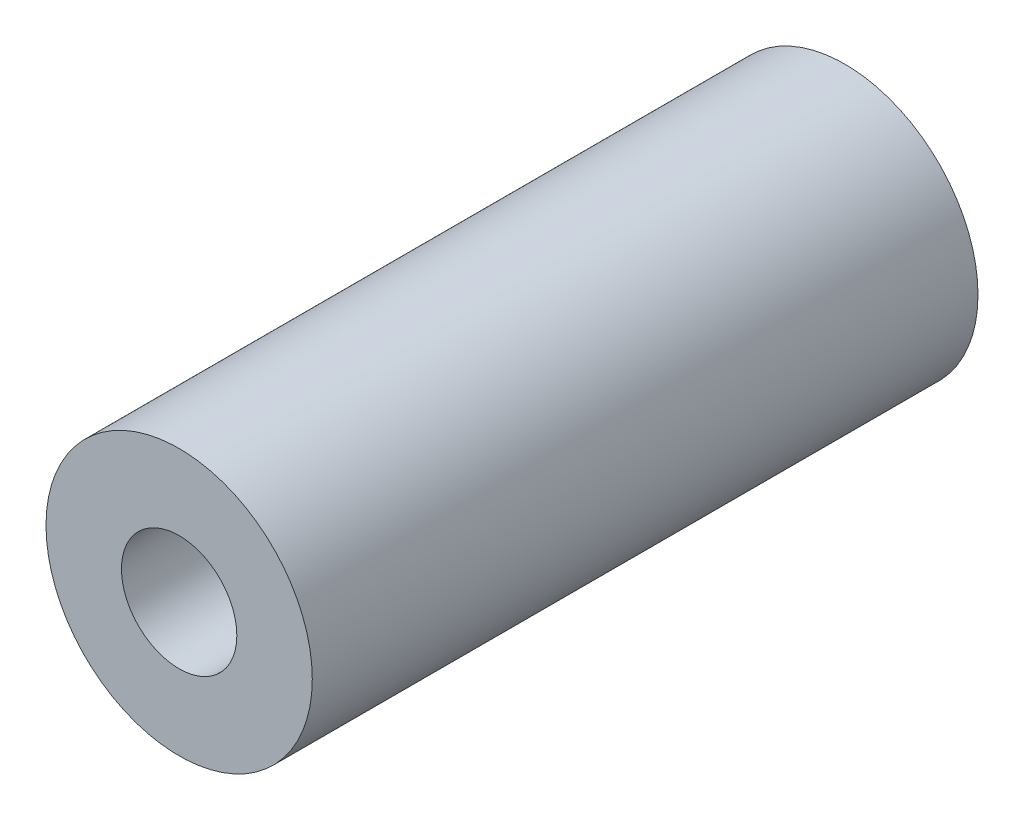
from build123d import *

# Parameters (mm, degrees)
SKETCH1_R           = 6
SKETCH1_R_2         = 2.6
BOSS_EXTRUDE1_DEPTH = 30


with BuildPart() as part:
    # Sketch1 → Boss-Extrude1 (new body)
    with BuildSketch(Plane.XY):
        Circle(SKETCH1_R)
        Circle(SKETCH1_R_2, mode=Mode.SUBTRACT)
    extrude(amount=BOSS_EXTRUDE1_DEPTH)


solid = part.part
